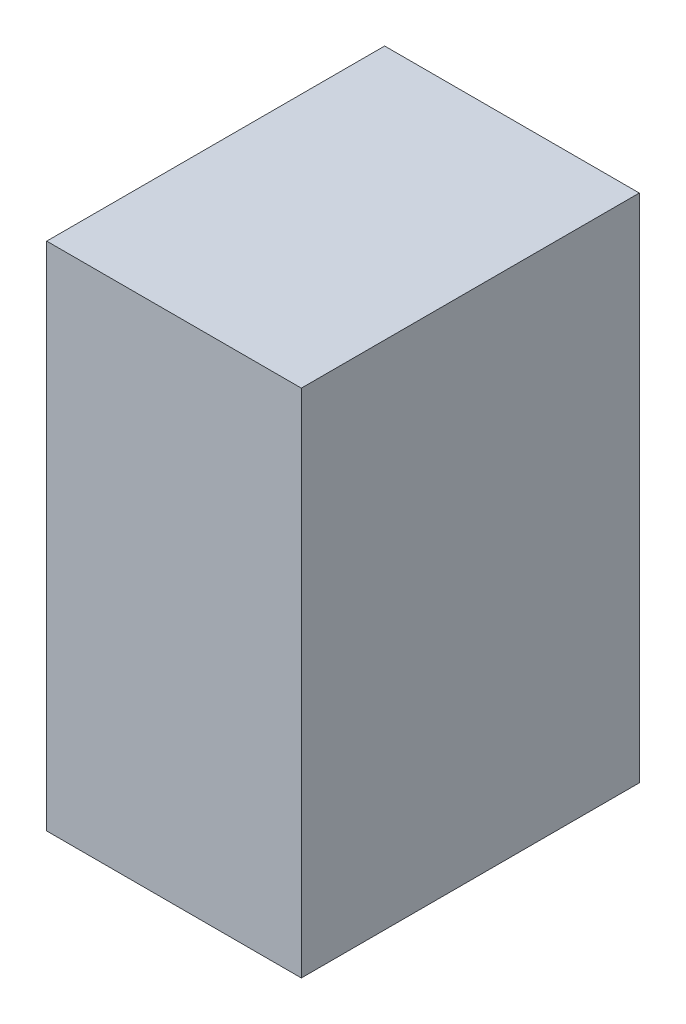
from build123d import *

# Parameters (mm, degrees)
SKETCH1_W           = 20.574
SKETCH1_H           = 41.275
BOSS_EXTRUDE1_DEPTH = 27.305


with BuildPart() as part:
    # Sketch1 → Boss-Extrude1 (new body)
    with BuildSketch(Plane.XY):
        with Locations((10.287, 20.6375)):
            Rectangle(SKETCH1_W, SKETCH1_H)
    extrude(amount=BOSS_EXTRUDE1_DEPTH)


solid = part.part
